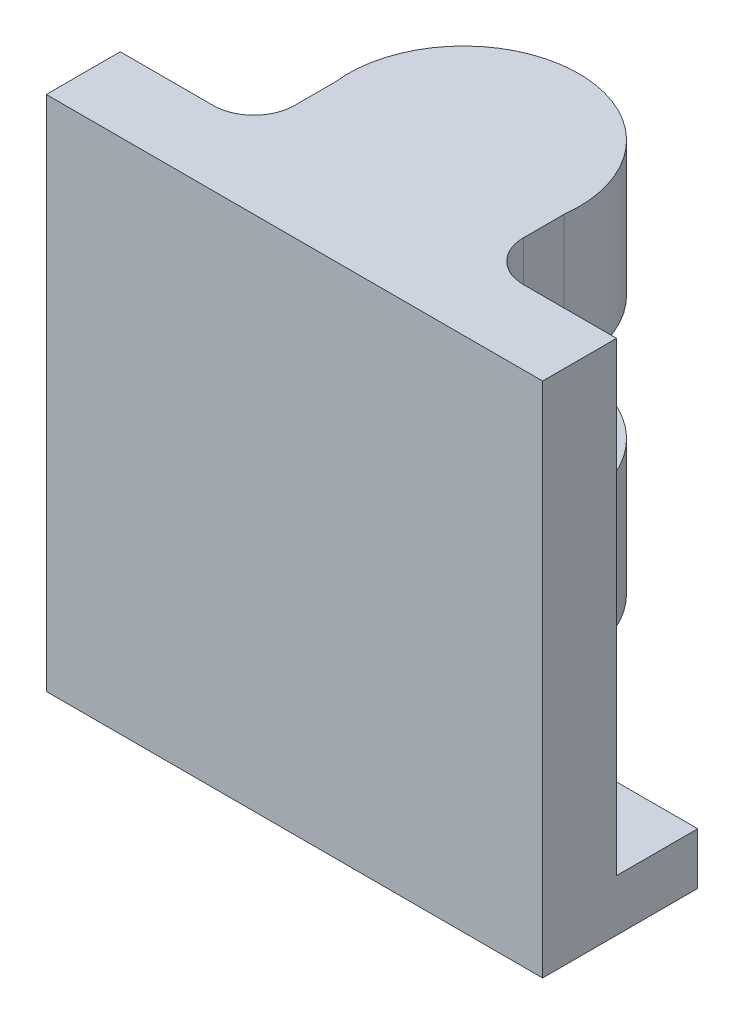
from build123d import *

# Parameters (mm, degrees)
SKETCH2_W           = 96
SKETCH2_H           = 30
SKETCH2_R           = 1.5
BOSS_EXTRUDE2_DEPTH = 10
BOSS_EXTRUDE4_DEPTH = 100
BOSS_EXTRUDE5_DEPTH = 26
LPATTERN1_COUNT     = 2
LPATTERN1_PITCH     = 50


with BuildPart() as part:
    # Sketch2 → Boss-Extrude2 (new body)
    with BuildSketch(Plane(origin=(0, 0, 0), x_dir=(1, 0, 0), z_dir=(0, 1, 0))):
        with Locations((0, 119.85)):
            Rectangle(SKETCH2_W, SKETCH2_H)
        with Locations((-30, 127)):
            Circle(SKETCH2_R, mode=Mode.SUBTRACT)
        with Locations((30, 127)):
            Circle(SKETCH2_R, mode=Mode.SUBTRACT)
    extrude(amount=BOSS_EXTRUDE2_DEPTH)

    # Sketch4 → Boss-Extrude4 (add)
    with BuildSketch(Plane(origin=(0, 0, 0), x_dir=(1, 0, 0), z_dir=(0, 1, 0))):
        with BuildLine():
            Line((-22.15, 134.85), (22.15, 134.85))
            Line((22.15, 134.85), (22.15, 127))
            ThreePointArc((22.15, 127), (24.449211768, 121.449211768), (30, 119.15))
            Line((30, 119.15), (48, 119.15))
            Line((48, 119.15), (48, 104.85))
            Line((48, 104.85), (-48, 104.85))
            Line((-48, 104.85), (-48, 119.15))
            Line((-48, 119.15), (-30, 119.15))
            ThreePointArc((-30, 119.15), (-24.449211768, 121.449211768), (-22.15, 127))
            Line((-22.15, 127), (-22.15, 134.85))
        make_face()
    extrude(amount=BOSS_EXTRUDE4_DEPTH)

    # Sketch6 → Boss-Extrude5 (add)
    with BuildSketch(Plane(origin=(0, 100, 0), x_dir=(1, 0, 0), z_dir=(0, 1, 0))):
        with BuildLine():
            Line((22.15, 134.85), (22.15, 104.85))
            Line((22.15, 104.85), (-22.15, 104.85))
            Line((-22.15, 104.85), (-22.15, 134.85))
            ThreePointArc((-22.15, 134.85), (0, 159.85), (22.15, 134.85))
        make_face()
    boss_extrude5 = extrude(amount=-BOSS_EXTRUDE5_DEPTH)

    # LPattern1: Boss-Extrude5 ×2
    with Locations(*[(0, -i * LPATTERN1_PITCH, 0) for i in range(1, LPATTERN1_COUNT)]):
        add(boss_extrude5)


solid = part.part
